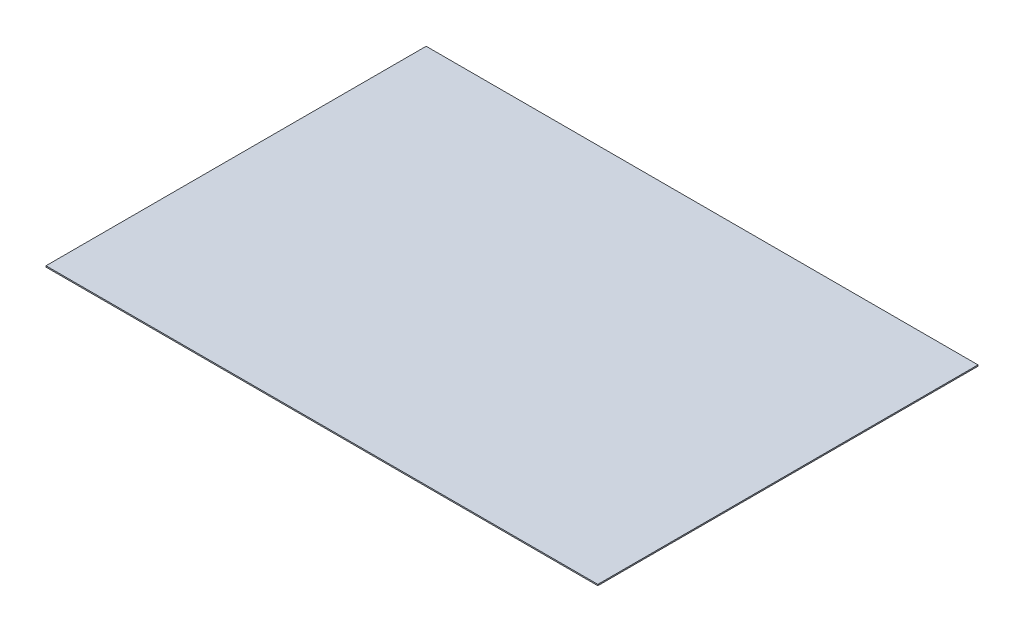
from build123d import *

# Parameters (mm, degrees)
SKETCH1_W           = 450
SKETCH1_H           = 310
BOSS_EXTRUDE1_DEPTH = 1


with BuildPart() as part:
    # Sketch1 → Boss-Extrude1 (new body)
    with BuildSketch(Plane(origin=(0, 0, 0), x_dir=(1, 0, 0), z_dir=(0, 1, 0))):
        Rectangle(SKETCH1_W, SKETCH1_H)
    extrude(amount=BOSS_EXTRUDE1_DEPTH)


solid = part.part
